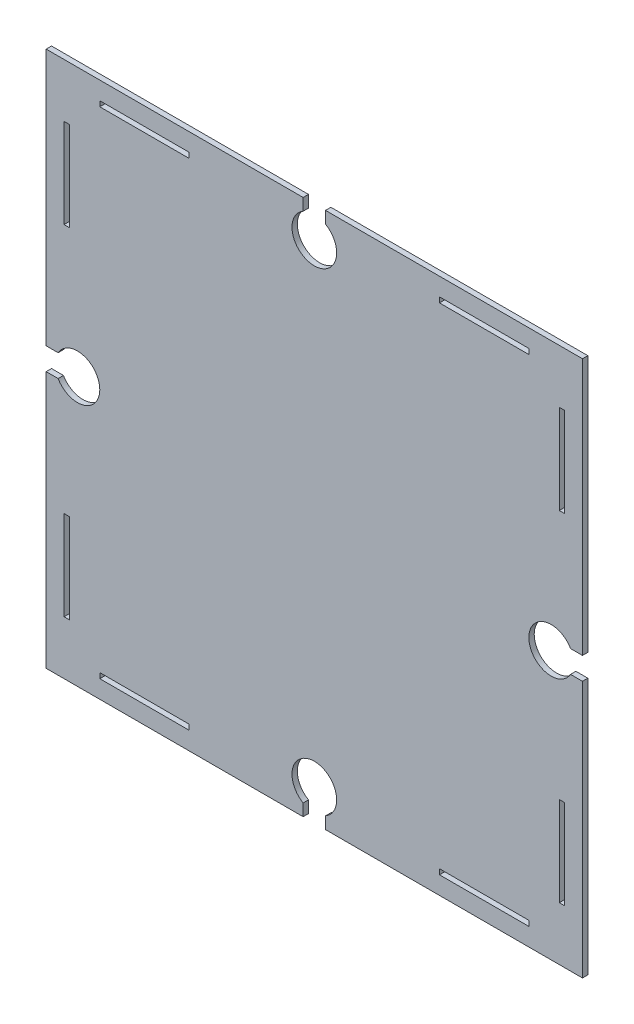
from build123d import *

# Parameters (mm, degrees)
ESQUISSE2_W             = 300
ESQUISSE2_H             = 300
BOSS_EXTRU_1_DEPTH      = 3
ESQUISSE3_W             = 50
ESQUISSE3_H             = 2.95
ESQUISSE3_W_2           = 2.95
ESQUISSE3_H_2           = 50
ENL_V_MAT_EXTRU_2_DEPTH = 6
ESQUISSE5_W             = 2.95
ESQUISSE5_H             = 50
ESQUISSE5_W_2           = 50
ESQUISSE5_H_2           = 2.95
ENL_V_MAT_EXTRU_3_DEPTH = 6
ENL_V_MAT_EXTRU_4_DEPTH = 6
SYM_TRIE2_COPY_1_DEPTH  = 6
SYM_TRIE2_COPY_2_DEPTH  = 6


with BuildPart() as part:
    # Esquisse2 → Boss.-Extru.1 (new body)
    with BuildSketch(Plane.XY):
        Rectangle(ESQUISSE2_W, ESQUISSE2_H)
    extrude(amount=BOSS_EXTRU_1_DEPTH)

    # Esquisse3 → Enlèv. mat.-Extru.2 (cut)
    with BuildSketch(Plane.XY.offset(3)):
        with Locations((-95, 138.525)):
            Rectangle(ESQUISSE3_W, ESQUISSE3_H)
        with Locations((-138.525, 95)):
            Rectangle(ESQUISSE3_W_2, ESQUISSE3_H_2)
    extrude(amount=-ENL_V_MAT_EXTRU_2_DEPTH, mode=Mode.SUBTRACT)

    # Esquisse5 → Enlèv. mat.-Extru.3 (cut)
    with BuildSketch(Plane(origin=(0, 0, 0), x_dir=(-1, 0, 0), z_dir=(0, 0, -1))):
        with Locations((138.525, -95)):
            Rectangle(ESQUISSE5_W, ESQUISSE5_H)
        with Locations((95, -138.525)):
            Rectangle(ESQUISSE5_W_2, ESQUISSE5_H_2)
        with Locations((-95, -138.525)):
            Rectangle(ESQUISSE5_W_2, ESQUISSE5_H_2)
        with Locations((-138.525, -95)):
            Rectangle(ESQUISSE5_W, ESQUISSE5_H)
        with Locations((-138.525, 95)):
            Rectangle(ESQUISSE5_W, ESQUISSE5_H)
        with Locations((-95, 138.525)):
            Rectangle(ESQUISSE5_W_2, ESQUISSE5_H_2)
    extrude(amount=-ENL_V_MAT_EXTRU_3_DEPTH, mode=Mode.SUBTRACT)

    # Esquisse6 → Enlèv. mat.-Extru.4 (cut)
    with BuildSketch(Plane(origin=(0, 0, 0), x_dir=(-1, 0, 0), z_dir=(0, 0, -1))):
        with BuildLine():
            Line((150, 6.25), (143.325317547, 6.25))
            ThreePointArc((143.325317547, 6.25), (120, 0), (143.325317547, -6.25))
            Line((143.325317547, -6.25), (150, -6.25))
            Line((150, -6.25), (150, 6.25))
        make_face()
        with BuildLine():
            Line((-6.25, -150), (6.25, -150))
            Line((6.25, -150), (6.25, -143.325317547))
            ThreePointArc((6.25, -143.325317547), (0, -120), (-6.25, -143.325317547))
            Line((-6.25, -143.325317547), (-6.25, -150))
        make_face()
    enl_v_mat_extru_4 = extrude(amount=-ENL_V_MAT_EXTRU_4_DEPTH, mode=Mode.SUBTRACT)

    # Symétrie1: Enlèv. mat.-Extru.4 across plane
    add(enl_v_mat_extru_4.mirror(Plane(origin=(0, 0, 0), x_dir=(0, 0, 1), z_dir=(1, 0, 0))), mode=Mode.SUBTRACT)

    # Symétrie2 copy 1 sketch → Symétrie2 copy 1 (cut)
    with BuildSketch(Plane(origin=(0, 0, 0), x_dir=(1, 0, 0), z_dir=(0, 0, -1))):
        with BuildLine():
            Line((150, 6.25), (143.325317547, 6.25))
            ThreePointArc((143.325317547, 6.25), (120, 0), (143.325317547, -6.25))
            Line((143.325317547, -6.25), (150, -6.25))
            Line((150, -6.25), (150, 6.25))
        make_face()
        with BuildLine():
            Line((-6.25, -150), (6.25, -150))
            Line((6.25, -150), (6.25, -143.325317547))
            ThreePointArc((6.25, -143.325317547), (0, -120), (-6.25, -143.325317547))
            Line((-6.25, -143.325317547), (-6.25, -150))
        make_face()
    extrude(amount=-SYM_TRIE2_COPY_1_DEPTH, mode=Mode.SUBTRACT)

    # Symétrie2 copy 2 sketch → Symétrie2 copy 2 (cut)
    with BuildSketch(Plane(origin=(0, 0, 0), x_dir=(-1, 0, 0), z_dir=(0, 0, -1))):
        with BuildLine():
            Line((150, -6.25), (143.325317547, -6.25))
            ThreePointArc((143.325317547, -6.25), (120, 0), (143.325317547, 6.25))
            Line((143.325317547, 6.25), (150, 6.25))
            Line((150, 6.25), (150, -6.25))
        make_face()
        with BuildLine():
            Line((-6.25, 150), (6.25, 150))
            Line((6.25, 150), (6.25, 143.325317547))
            ThreePointArc((6.25, 143.325317547), (0, 120), (-6.25, 143.325317547))
            Line((-6.25, 143.325317547), (-6.25, 150))
        make_face()
    extrude(amount=-SYM_TRIE2_COPY_2_DEPTH, mode=Mode.SUBTRACT)


solid = part.part
